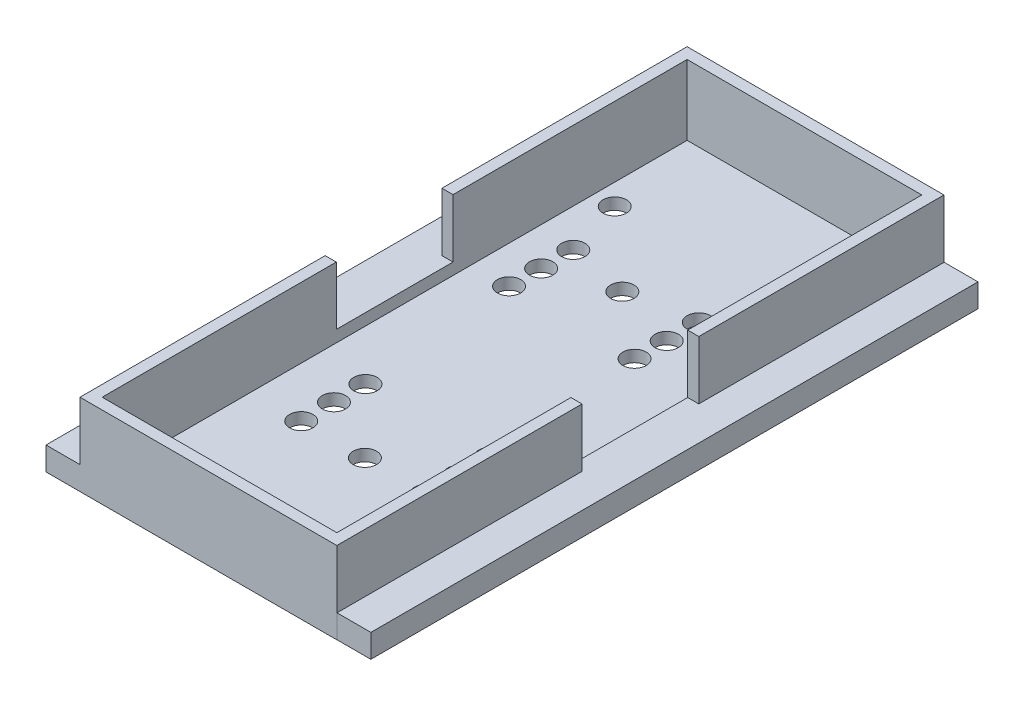
from build123d import *

# Parameters (mm, degrees)
SKETCH1_W               = 22
SKETCH1_H               = 52
BOSS_EXTRUDE1_DEPTH     = 7
SKETCH2_W               = 20.1
SKETCH2_H               = 50.1
CUT_EXTRUDE1_DEPTH      = 6
CUT_EXTRUDE6_DEPTH      = 29.861739379
CUT_EXTRUDE6_DEPTH_BACK = 29.861739379
SKETCH7_R               = 0.8
CUT_EXTRUDE7_REACH      = 30.862
SKETCH8_R               = 1
CUT_EXTRUDE9_REACH      = 30.862
SKETCH9_R               = 1
CUT_EXTRUDE10_REACH     = 30.862
SKETCH10_R              = 1
CUT_EXTRUDE11_REACH     = 30.862
SKETCH11_R              = 1
CUT_EXTRUDE12_REACH     = 30.862
SKETCH12_R              = 1
CUT_EXTRUDE13_REACH     = 30.862
SKETCH13_R              = 1
CUT_EXTRUDE14_REACH     = 30.862
SKETCH14_R              = 1
CUT_EXTRUDE15_REACH     = 30.862
SKETCH15_R              = 1
CUT_EXTRUDE16_REACH     = 30.862
SKETCH16_R              = 1
SKETCH18_W              = 2.91
SKETCH18_H              = 52
BOSS_EXTRUDE2_DEPTH     = 2
SKETCH18_3_W            = 2.9
SKETCH18_3_H            = 52
BOSS_EXTRUDE3_DEPTH     = 2
SKETCH19_W              = 10
SKETCH19_H              = 5
CUT_EXTRUDE17_DEPTH     = 37.683583771


with BuildPart() as part:
    # Sketch1 → Boss-Extrude1 (new body)
    with BuildSketch(Plane(origin=(0, 0, 0), x_dir=(1, 0, 0), z_dir=(0, 1, 0))):
        Rectangle(SKETCH1_W, SKETCH1_H)
    extrude(amount=BOSS_EXTRUDE1_DEPTH)

    # Sketch2 → Cut-Extrude1 (cut)
    with BuildSketch(Plane(origin=(0, 7, 0), x_dir=(1, 0, 0), z_dir=(0, 1, 0))):
        Rectangle(SKETCH2_W, SKETCH2_H)
    extrude(amount=-CUT_EXTRUDE1_DEPTH, mode=Mode.SUBTRACT)

    # Sketch7 → Cut-Extrude6 (cut, two sides: drawn at the far end of the back side and taken through both)
    with BuildSketch(Plane(origin=(0, 1, 0), x_dir=(1, 0, 0), z_dir=(0, 1, 0)).offset(-CUT_EXTRUDE6_DEPTH_BACK)):
        with Locations((-8.15, -23)):
            Circle(SKETCH7_R)
    extrude(amount=CUT_EXTRUDE6_DEPTH + CUT_EXTRUDE6_DEPTH_BACK, mode=Mode.SUBTRACT)

    # Sketch8 → Cut-Extrude7 (cut, up to next)
    with BuildSketch(Plane(origin=(0, 1, 0), x_dir=(1, 0, 0), z_dir=(0, 1, 0)), mode=Mode.PRIVATE) as cut_extrude7_sk1:
        with Locations((-5.75, -12.3)):
            Circle(SKETCH8_R)
    cut_extrude7_tool1 = extrude(cut_extrude7_sk1.sketch, amount=-CUT_EXTRUDE7_REACH, mode=Mode.PRIVATE) & part.part
    # Sketch8 → Cut-Extrude7 (cut, up to next)
    with BuildSketch(Plane(origin=(0, 1, 0), x_dir=(1, 0, 0), z_dir=(0, 1, 0)), mode=Mode.PRIVATE) as cut_extrude7_sk2:
        with Locations((5, -12.3)):
            Circle(SKETCH8_R)
    cut_extrude7_tool2 = extrude(cut_extrude7_sk2.sketch, amount=-CUT_EXTRUDE7_REACH, mode=Mode.PRIVATE) & part.part
    add(cut_extrude7_tool1.solids().sort_by_distance((-5.75, 1, 12.3))[0], mode=Mode.SUBTRACT)
    add(cut_extrude7_tool2.solids().sort_by_distance((5, 1, 12.3))[0], mode=Mode.SUBTRACT)

    # Sketch9 → Cut-Extrude9 (cut, up to next)
    with BuildSketch(Plane(origin=(0, 1, 0), x_dir=(1, 0, 0), z_dir=(0, 1, 0)), mode=Mode.PRIVATE) as cut_extrude9_sk1:
        with Locations((-5.75, -9.5)):
            Circle(SKETCH9_R)
    cut_extrude9_tool1 = extrude(cut_extrude9_sk1.sketch, amount=-CUT_EXTRUDE9_REACH, mode=Mode.PRIVATE) & part.part
    # Sketch9 → Cut-Extrude9 (cut, up to next)
    with BuildSketch(Plane(origin=(0, 1, 0), x_dir=(1, 0, 0), z_dir=(0, 1, 0)), mode=Mode.PRIVATE) as cut_extrude9_sk2:
        with Locations((5, -9.5)):
            Circle(SKETCH9_R)
    cut_extrude9_tool2 = extrude(cut_extrude9_sk2.sketch, amount=-CUT_EXTRUDE9_REACH, mode=Mode.PRIVATE) & part.part
    add(cut_extrude9_tool1.solids().sort_by_distance((-5.75, 1, 9.5))[0], mode=Mode.SUBTRACT)
    add(cut_extrude9_tool2.solids().sort_by_distance((5, 1, 9.5))[0], mode=Mode.SUBTRACT)

    # Sketch10 → Cut-Extrude10 (cut, up to next)
    with BuildSketch(Plane(origin=(0, 1, 0), x_dir=(1, 0, 0), z_dir=(0, 1, 0)), mode=Mode.PRIVATE) as cut_extrude10_sk1:
        with Locations((-5.75, -6.8)):
            Circle(SKETCH10_R)
    cut_extrude10_tool1 = extrude(cut_extrude10_sk1.sketch, amount=-CUT_EXTRUDE10_REACH, mode=Mode.PRIVATE) & part.part
    # Sketch10 → Cut-Extrude10 (cut, up to next)
    with BuildSketch(Plane(origin=(0, 1, 0), x_dir=(1, 0, 0), z_dir=(0, 1, 0)), mode=Mode.PRIVATE) as cut_extrude10_sk2:
        with Locations((5, -6.837159935)):
            Circle(SKETCH10_R)
    cut_extrude10_tool2 = extrude(cut_extrude10_sk2.sketch, amount=-CUT_EXTRUDE10_REACH, mode=Mode.PRIVATE) & part.part
    add(cut_extrude10_tool1.solids().sort_by_distance((-5.75, 1, 6.8))[0], mode=Mode.SUBTRACT)
    add(cut_extrude10_tool2.solids().sort_by_distance((5, 1, 6.83716))[0], mode=Mode.SUBTRACT)

    # Sketch11 → Cut-Extrude11 (cut, up to next)
    with BuildSketch(Plane(origin=(0, 1, 0), x_dir=(1, 0, 0), z_dir=(0, 1, 0)), mode=Mode.PRIVATE) as cut_extrude11_sk1:
        with Locations((-0.3, -12.3)):
            Circle(SKETCH11_R)
    cut_extrude11_tool1 = extrude(cut_extrude11_sk1.sketch, amount=-CUT_EXTRUDE11_REACH, mode=Mode.PRIVATE) & part.part
    add(cut_extrude11_tool1.solids().sort_by_distance((-0.3, 1, 12.3))[0], mode=Mode.SUBTRACT)

    # Sketch12 → Cut-Extrude12 (cut, up to next)
    with BuildSketch(Plane(origin=(0, 1, 0), x_dir=(1, 0, 0), z_dir=(0, 1, 0)), mode=Mode.PRIVATE) as cut_extrude12_sk1:
        with Locations((3.95, 12.05)):
            Circle(SKETCH12_R)
    cut_extrude12_tool1 = extrude(cut_extrude12_sk1.sketch, amount=-CUT_EXTRUDE12_REACH, mode=Mode.PRIVATE) & part.part
    # Sketch12 → Cut-Extrude12 (cut, up to next)
    with BuildSketch(Plane(origin=(0, 1, 0), x_dir=(1, 0, 0), z_dir=(0, 1, 0)), mode=Mode.PRIVATE) as cut_extrude12_sk2:
        with Locations((-6.8, 12.05)):
            Circle(SKETCH12_R)
    cut_extrude12_tool2 = extrude(cut_extrude12_sk2.sketch, amount=-CUT_EXTRUDE12_REACH, mode=Mode.PRIVATE) & part.part
    add(cut_extrude12_tool1.solids().sort_by_distance((3.95, 1, -12.05))[0], mode=Mode.SUBTRACT)
    add(cut_extrude12_tool2.solids().sort_by_distance((-6.8, 1, -12.05))[0], mode=Mode.SUBTRACT)

    # Sketch13 → Cut-Extrude13 (cut, up to next)
    with BuildSketch(Plane(origin=(0, 1, 0), x_dir=(1, 0, 0), z_dir=(0, 1, 0)), mode=Mode.PRIVATE) as cut_extrude13_sk1:
        with Locations((3.95, 9.3)):
            Circle(SKETCH13_R)
    cut_extrude13_tool1 = extrude(cut_extrude13_sk1.sketch, amount=-CUT_EXTRUDE13_REACH, mode=Mode.PRIVATE) & part.part
    # Sketch13 → Cut-Extrude13 (cut, up to next)
    with BuildSketch(Plane(origin=(0, 1, 0), x_dir=(1, 0, 0), z_dir=(0, 1, 0)), mode=Mode.PRIVATE) as cut_extrude13_sk2:
        with Locations((-6.8, 9.3)):
            Circle(SKETCH13_R)
    cut_extrude13_tool2 = extrude(cut_extrude13_sk2.sketch, amount=-CUT_EXTRUDE13_REACH, mode=Mode.PRIVATE) & part.part
    add(cut_extrude13_tool1.solids().sort_by_distance((3.95, 1, -9.3))[0], mode=Mode.SUBTRACT)
    add(cut_extrude13_tool2.solids().sort_by_distance((-6.8, 1, -9.3))[0], mode=Mode.SUBTRACT)

    # Sketch14 → Cut-Extrude14 (cut, up to next)
    with BuildSketch(Plane(origin=(0, 1, 0), x_dir=(1, 0, 0), z_dir=(0, 1, 0)), mode=Mode.PRIVATE) as cut_extrude14_sk1:
        with Locations((3.9, 6.6)):
            Circle(SKETCH14_R)
    cut_extrude14_tool1 = extrude(cut_extrude14_sk1.sketch, amount=-CUT_EXTRUDE14_REACH, mode=Mode.PRIVATE) & part.part
    # Sketch14 → Cut-Extrude14 (cut, up to next)
    with BuildSketch(Plane(origin=(0, 1, 0), x_dir=(1, 0, 0), z_dir=(0, 1, 0)), mode=Mode.PRIVATE) as cut_extrude14_sk2:
        with Locations((-6.85, 6.6)):
            Circle(SKETCH14_R)
    cut_extrude14_tool2 = extrude(cut_extrude14_sk2.sketch, amount=-CUT_EXTRUDE14_REACH, mode=Mode.PRIVATE) & part.part
    add(cut_extrude14_tool1.solids().sort_by_distance((3.9, 1, -6.6))[0], mode=Mode.SUBTRACT)
    add(cut_extrude14_tool2.solids().sort_by_distance((-6.85, 1, -6.6))[0], mode=Mode.SUBTRACT)

    # Sketch15 → Cut-Extrude15 (cut, up to next)
    with BuildSketch(Plane(origin=(0, 1, 0), x_dir=(1, 0, 0), z_dir=(0, 1, 0)), mode=Mode.PRIVATE) as cut_extrude15_sk1:
        with Locations((-1.6, 11.05)):
            Circle(SKETCH15_R)
    cut_extrude15_tool1 = extrude(cut_extrude15_sk1.sketch, amount=-CUT_EXTRUDE15_REACH, mode=Mode.PRIVATE) & part.part
    add(cut_extrude15_tool1.solids().sort_by_distance((-1.6, 1, -11.05))[0], mode=Mode.SUBTRACT)

    # Sketch16 → Cut-Extrude16 (cut, up to next)
    with BuildSketch(Plane(origin=(0, 1, 0), x_dir=(1, 0, 0), z_dir=(0, 1, 0)), mode=Mode.PRIVATE) as cut_extrude16_sk1:
        with Locations((-8.25, 17.05)):
            Circle(SKETCH16_R)
    cut_extrude16_tool1 = extrude(cut_extrude16_sk1.sketch, amount=-CUT_EXTRUDE16_REACH, mode=Mode.PRIVATE) & part.part
    add(cut_extrude16_tool1.solids().sort_by_distance((-8.25, 1, -17.05))[0], mode=Mode.SUBTRACT)

    # Sketch18 → Boss-Extrude2 (add)
    with BuildSketch(Plane.XZ):
        with Locations((-12.455, 0)):
            Rectangle(SKETCH18_W, SKETCH18_H)
    extrude(amount=-BOSS_EXTRUDE2_DEPTH)

    # Sketch18_3 → Boss-Extrude3 (add)
    with BuildSketch(Plane.XZ):
        with Locations((12.45, -0.012983648)):
            Rectangle(SKETCH18_3_W, SKETCH18_3_H)
    extrude(amount=-BOSS_EXTRUDE3_DEPTH)

    # Sketch19 → Cut-Extrude17 (cut, through all)
    with BuildSketch(Plane.ZY.offset(11)):
        with Locations((0, 4.5)):
            Rectangle(SKETCH19_W, SKETCH19_H)
    extrude(amount=-CUT_EXTRUDE17_DEPTH, mode=Mode.SUBTRACT)


solid = part.part
